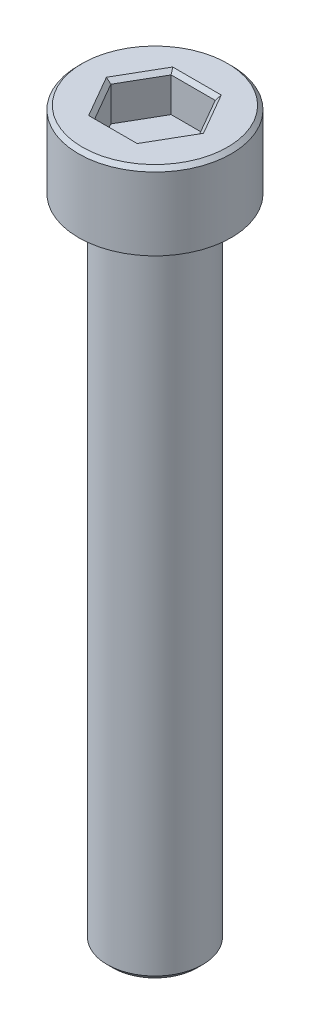
from build123d import *

# Parameters (mm, degrees)
SKETCH_1_R          = 4
EXTRUDE_1_DEPTH     = 4
SKETCH_2_R          = 2.5
EXTRUDE_2_DEPTH     = 34
CUT_EXTRUDE_1_DEPTH = 2
CHAMFER_1_SIZE      = 0.2
CHAMFER_2_SIZE      = 0.3


with BuildPart() as part:
    # 草图1 → 凸台-拉伸1 (new body)
    with BuildSketch(Plane(origin=(0, 0, 0), x_dir=(1, 0, 0), z_dir=(0, 1, 0))):
        Circle(SKETCH_1_R)
    extrude(amount=EXTRUDE_1_DEPTH)

    # 草图2 → 凸台-拉伸2 (add)
    with BuildSketch(Plane.XZ):
        Circle(SKETCH_2_R)
    extrude(amount=EXTRUDE_2_DEPTH)

    # 草图11 → 切除-拉伸1 (cut)
    with BuildSketch(Plane(origin=(0, 4, 0), x_dir=(1, 0, 0), z_dir=(0, 1, 0))):
        Polygon((1.154954177, 1.999853541), (-1.154446882, 2.000146427), (-2.309401058, 0.000292887), (-1.154954177, -1.999853541), (1.154446882, -2.000146427), (2.309401058, -0.000292887), align=None)
    extrude(amount=-CUT_EXTRUDE_1_DEPTH, mode=Mode.SUBTRACT)

    # 倒角1
    chamfer_1_edges = [part.edges().sort_by_distance(p)[0] for p in [
        (1.732177617, 4, -0.999780327),
        (0.000253647, 4, -1.999999984),
        (-1.73192397, 4, -1.000219657),
        (-1.732177617, 4, 0.999780327),
        (-0.000253647, 4, 1.999999984),
        (1.73192397, 4, 1.000219657),
        (-4, 4, 0),
    ]]
    chamfer(chamfer_1_edges, length=CHAMFER_1_SIZE)

    # 倒角2
    chamfer_2_edges = [part.edges().sort_by_distance(p)[0] for p in [
        (-2.5, -34, 0),
    ]]
    chamfer(chamfer_2_edges, length=CHAMFER_2_SIZE)


solid = part.part
